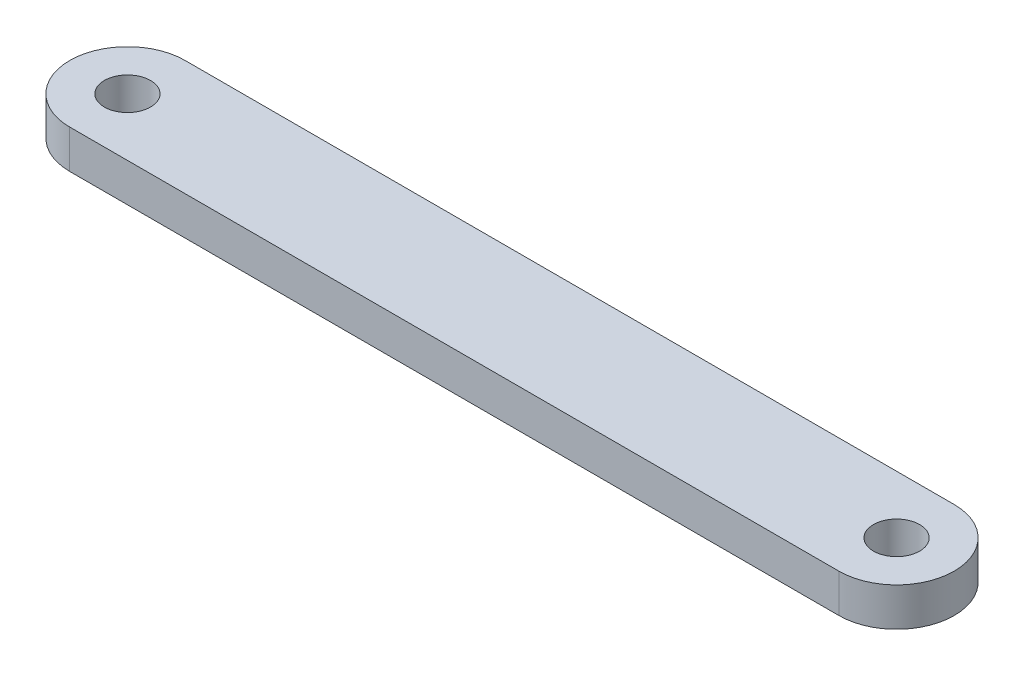
from build123d import *

# Parameters (mm, degrees)
SKETCH1_R           = 3
BOSS_EXTRUDE1_DEPTH = 5


with BuildPart() as part:
    # Sketch1 → Boss-Extrude1 (new body)
    with BuildSketch(Plane(origin=(0, 0, 0), x_dir=(1, 0, 0), z_dir=(0, 1, 0))):
        with BuildLine():
            Line((0, 7.5), (100, 7.5))
            ThreePointArc((100, 7.5), (107.5, 0), (100, -7.5))
            Line((100, -7.5), (0, -7.5))
            ThreePointArc((0, -7.5), (-7.5, 0), (0, 7.5))
        make_face()
        with Locations((100, 0)):
            Circle(SKETCH1_R, mode=Mode.SUBTRACT)
        Circle(SKETCH1_R, mode=Mode.SUBTRACT)
    extrude(amount=BOSS_EXTRUDE1_DEPTH)


solid = part.part
